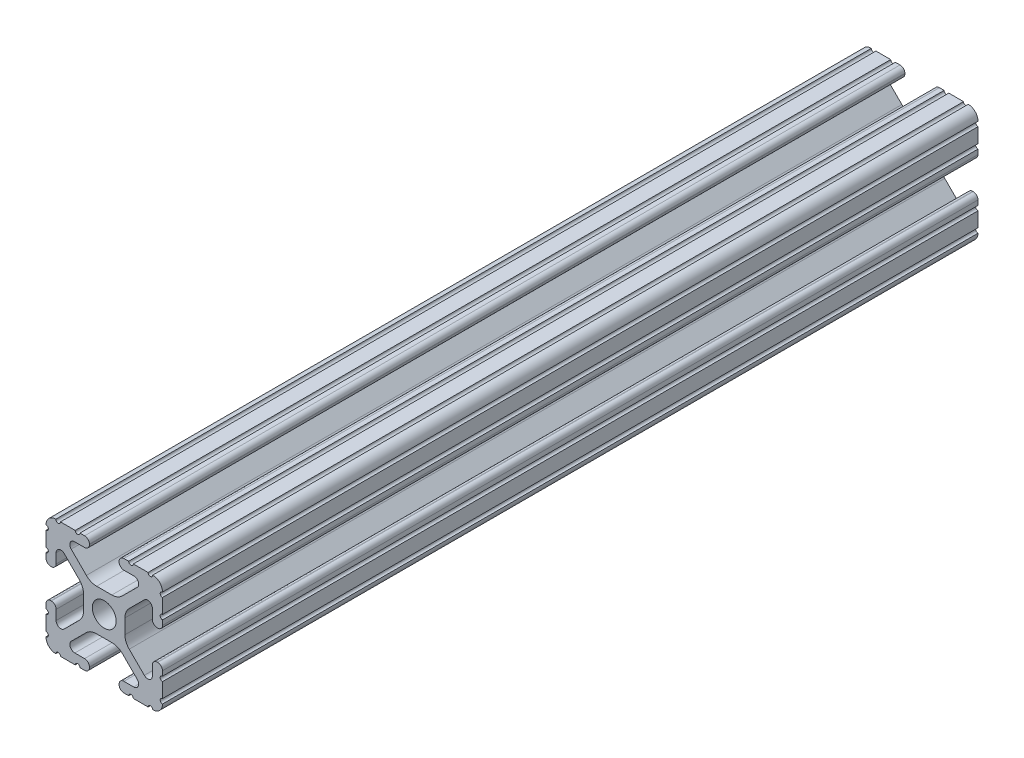
from build123d import *

# Parameters (mm, degrees)
SKETCH1_R           = 2.6035
BOSS_EXTRUDE1_DEPTH = 2463.8
CUT_EXTRUDE1_DEPTH  = 2286


with BuildPart() as part:
    # Sketch1 → Boss-Extrude1 (new body)
    with BuildSketch(Plane.XY):
        with BuildLine():
            Line((-1.709253557, -4.4958), (1.709253557, -4.4958))
            ThreePointArc((1.709253557, -4.4958), (2.922936451, -4.736929036), (3.952270251, -5.423690499))
            Line((3.952270251, -5.423690499), (7.179650497, -8.645192506))
            ThreePointArc((7.179650497, -8.645192506), (7.41473083, -9.822813117), (6.416408329, -10.4902))
            Line((6.416408329, -10.4902), (4.287512407, -10.4902))
            ThreePointArc((4.287512407, -10.4902), (3.54574862, -10.79744862), (3.2385, -11.539212407))
            Line((3.2385, -11.539212407), (3.2385, -11.650987593))
            ThreePointArc((3.2385, -11.650987593), (3.54574862, -12.39275138), (4.287512407, -12.7))
            Line((4.287512407, -12.7), (5.317126718, -12.7))
            ThreePointArc((5.317126718, -12.7), (5.825126718, -12.192), (6.333126718, -12.7))
            Line((6.333126718, -12.7), (9.550443118, -12.7))
            ThreePointArc((9.550443118, -12.7), (10.058366869, -12.192000006), (10.566443095, -12.699847501))
            ThreePointArc((10.566443095, -12.699847501), (12.082537762, -12.08250727), (12.699846982, -10.566399977))
            ThreePointArc((12.699846982, -10.566399977), (12.192000006, -10.058323491), (12.7, -9.5504))
            Line((12.7, -9.5504), (12.7, -6.3330836))
            ThreePointArc((12.7, -6.3330836), (12.192, -5.8250836), (12.7, -5.3170836))
            Line((12.7, -5.3170836), (12.7, -4.287469289))
            ThreePointArc((12.7, -4.287469289), (12.39275138, -3.545705502), (11.650987593, -3.238456882))
            Line((11.650987593, -3.238456882), (11.539212407, -3.238456882))
            ThreePointArc((11.539212407, -3.238456882), (10.79744862, -3.545705502), (10.4902, -4.287469289))
            Line((10.4902, -4.287469289), (10.4902, -6.402089023))
            ThreePointArc((10.4902, -6.402089023), (9.856505071, -7.351067942), (8.737131347, -7.129408934))
            Line((8.737131347, -7.129408934), (5.441005833, -3.840816462))
            ThreePointArc((5.441005833, -3.840816462), (4.750877967, -2.809883091), (4.5085, -1.593185507))
            Line((4.5085, -1.593185507), (4.5085, 1.593185507))
            ThreePointArc((4.5085, 1.593185507), (4.750877967, 2.809883091), (5.441005833, 3.840816462))
            Line((5.441005833, 3.840816462), (8.737131347, 7.129408934))
            ThreePointArc((8.737131347, 7.129408934), (9.856505071, 7.351067942), (10.4902, 6.402089023))
            Line((10.4902, 6.402089023), (10.4902, 4.287469289))
            ThreePointArc((10.4902, 4.287469289), (10.79744862, 3.545705502), (11.539212407, 3.238456882))
            Line((11.539212407, 3.238456882), (11.650987593, 3.238456882))
            ThreePointArc((11.650987593, 3.238456882), (12.39275138, 3.545705502), (12.7, 4.287469289))
            Line((12.7, 4.287469289), (12.7, 5.3170836))
            ThreePointArc((12.7, 5.3170836), (12.192, 5.8250836), (12.7, 6.3330836))
            Line((12.7, 6.3330836), (12.7, 9.5504))
            ThreePointArc((12.7, 9.5504), (12.192000006, 10.058323491), (12.699846982, 10.566399977))
            ThreePointArc((12.699846982, 10.566399977), (12.082537762, 12.08250727), (10.566443095, 12.699847501))
            ThreePointArc((10.566443095, 12.699847501), (10.058366869, 12.192000006), (9.550443118, 12.7))
            Line((9.550443118, 12.7), (6.333126718, 12.7))
            ThreePointArc((6.333126718, 12.7), (5.825126718, 12.192), (5.317126718, 12.7))
            Line((5.317126718, 12.7), (4.287512407, 12.7))
            ThreePointArc((4.287512407, 12.7), (3.54574862, 12.39275138), (3.2385, 11.650987593))
            Line((3.2385, 11.650987593), (3.2385, 11.539212407))
            ThreePointArc((3.2385, 11.539212407), (3.54574862, 10.79744862), (4.287512407, 10.4902))
            Line((4.287512407, 10.4902), (6.476788598, 10.4902))
            ThreePointArc((6.476788598, 10.4902), (7.432222385, 9.85140422), (7.207036008, 8.724370562))
            Line((7.207036008, 8.724370562), (3.898272566, 5.423169045))
            ThreePointArc((3.898272566, 5.423169045), (2.869120213, 4.736787962), (1.655778399, 4.4958))
            Line((1.655778399, 4.4958), (-1.655778399, 4.4958))
            ThreePointArc((-1.655778399, 4.4958), (-2.869120213, 4.736787962), (-3.898272566, 5.423169045))
            Line((-3.898272566, 5.423169045), (-7.207036008, 8.724370562))
            ThreePointArc((-7.207036008, 8.724370562), (-7.432222385, 9.85140422), (-6.476788598, 10.4902))
            Line((-6.476788598, 10.4902), (-4.287512407, 10.4902))
            ThreePointArc((-4.287512407, 10.4902), (-3.54574862, 10.79744862), (-3.2385, 11.539212407))
            Line((-3.2385, 11.539212407), (-3.2385, 11.650987593))
            ThreePointArc((-3.2385, 11.650987593), (-3.54574862, 12.39275138), (-4.287512407, 12.7))
            Line((-4.287512407, 12.7), (-5.317126718, 12.7))
            ThreePointArc((-5.317126718, 12.7), (-5.825126718, 12.192), (-6.333126718, 12.7))
            Line((-6.333126718, 12.7), (-9.550443118, 12.7))
            ThreePointArc((-9.550443118, 12.7), (-10.058366869, 12.192000006), (-10.566443095, 12.699847501))
            ThreePointArc((-10.566443095, 12.699847501), (-12.082537762, 12.08250727), (-12.699846982, 10.566399977))
            ThreePointArc((-12.699846982, 10.566399977), (-12.192000006, 10.058323491), (-12.7, 9.5504))
            Line((-12.7, 9.5504), (-12.7, 6.3330836))
            ThreePointArc((-12.7, 6.3330836), (-12.192, 5.8250836), (-12.7, 5.3170836))
            Line((-12.7, 5.3170836), (-12.7, 4.287469289))
            ThreePointArc((-12.7, 4.287469289), (-12.39275138, 3.545705502), (-11.650987593, 3.238456882))
            Line((-11.650987593, 3.238456882), (-11.539212407, 3.238456882))
            ThreePointArc((-11.539212407, 3.238456882), (-10.79744862, 3.545705502), (-10.4902, 4.287469289))
            Line((-10.4902, 4.287469289), (-10.4902, 6.402089023))
            ThreePointArc((-10.4902, 6.402089023), (-9.856505071, 7.351067942), (-8.737131347, 7.129408934))
            Line((-8.737131347, 7.129408934), (-5.441005833, 3.840816462))
            ThreePointArc((-5.441005833, 3.840816462), (-4.750877967, 2.809883091), (-4.5085, 1.593185507))
            Line((-4.5085, 1.593185507), (-4.5085, -1.593185507))
            ThreePointArc((-4.5085, -1.593185507), (-4.750877967, -2.809883091), (-5.441005833, -3.840816462))
            Line((-5.441005833, -3.840816462), (-8.737131347, -7.129408934))
            ThreePointArc((-8.737131347, -7.129408934), (-9.856505071, -7.351067942), (-10.4902, -6.402089023))
            Line((-10.4902, -6.402089023), (-10.4902, -4.287469289))
            ThreePointArc((-10.4902, -4.287469289), (-10.79744862, -3.545705502), (-11.539212407, -3.238456882))
            Line((-11.539212407, -3.238456882), (-11.650987593, -3.238456882))
            ThreePointArc((-11.650987593, -3.238456882), (-12.39275138, -3.545705502), (-12.7, -4.287469289))
            Line((-12.7, -4.287469289), (-12.7, -5.3170836))
            ThreePointArc((-12.7, -5.3170836), (-12.192, -5.8250836), (-12.7, -6.3330836))
            Line((-12.7, -6.3330836), (-12.7, -9.5504))
            ThreePointArc((-12.7, -9.5504), (-12.192000006, -10.058323491), (-12.699846982, -10.566399977))
            ThreePointArc((-12.699846982, -10.566399977), (-12.082537762, -12.08250727), (-10.566443095, -12.699847501))
            ThreePointArc((-10.566443095, -12.699847501), (-10.058366869, -12.192000006), (-9.550443118, -12.7))
            Line((-9.550443118, -12.7), (-6.333126718, -12.7))
            ThreePointArc((-6.333126718, -12.7), (-5.825126718, -12.192), (-5.317126718, -12.7))
            Line((-5.317126718, -12.7), (-4.287512407, -12.7))
            ThreePointArc((-4.287512407, -12.7), (-3.54574862, -12.39275138), (-3.2385, -11.650987593))
            Line((-3.2385, -11.650987593), (-3.2385, -11.539212407))
            ThreePointArc((-3.2385, -11.539212407), (-3.54574862, -10.79744862), (-4.287512407, -10.4902))
            Line((-4.287512407, -10.4902), (-6.416408329, -10.4902))
            ThreePointArc((-6.416408329, -10.4902), (-7.41473083, -9.822813117), (-7.179650497, -8.645192506))
            Line((-7.179650497, -8.645192506), (-3.952270251, -5.423690499))
            ThreePointArc((-3.952270251, -5.423690499), (-2.922936451, -4.736929036), (-1.709253557, -4.4958))
        make_face()
        Circle(SKETCH1_R, mode=Mode.SUBTRACT)
    extrude(amount=BOSS_EXTRUDE1_DEPTH)

    # Sketch2 → Cut-Extrude1 (cut)
    with BuildSketch(Plane.XY.offset(2463.8)):
        with BuildLine():
            Line((-1.709253557, -4.4958), (1.709253557, -4.4958))
            ThreePointArc((1.709253557, -4.4958), (2.922936451, -4.736929036), (3.952270251, -5.423690499))
            Line((3.952270251, -5.423690499), (7.179650497, -8.645192506))
            ThreePointArc((7.179650497, -8.645192506), (7.41473083, -9.822813117), (6.416408329, -10.4902))
            Line((6.416408329, -10.4902), (4.287512407, -10.4902))
            ThreePointArc((4.287512407, -10.4902), (3.54574862, -10.79744862), (3.2385, -11.539212407))
            Line((3.2385, -11.539212407), (3.2385, -11.650987593))
            ThreePointArc((3.2385, -11.650987593), (3.54574862, -12.39275138), (4.287512407, -12.7))
            Line((4.287512407, -12.7), (5.317126718, -12.7))
            ThreePointArc((5.317126718, -12.7), (5.825126718, -12.192), (6.333126718, -12.7))
            Line((6.333126718, -12.7), (9.550443118, -12.7))
            ThreePointArc((9.550443118, -12.7), (10.058366869, -12.192000006), (10.566443095, -12.699847501))
            ThreePointArc((10.566443095, -12.699847501), (12.082537762, -12.08250727), (12.699846982, -10.566399977))
            ThreePointArc((12.699846982, -10.566399977), (12.192000006, -10.058323491), (12.7, -9.5504))
            Line((12.7, -9.5504), (12.7, -6.3330836))
            ThreePointArc((12.7, -6.3330836), (12.192, -5.8250836), (12.7, -5.3170836))
            Line((12.7, -5.3170836), (12.7, -4.287469289))
            ThreePointArc((12.7, -4.287469289), (12.39275138, -3.545705502), (11.650987593, -3.238456882))
            Line((11.650987593, -3.238456882), (11.539212407, -3.238456882))
            ThreePointArc((11.539212407, -3.238456882), (10.79744862, -3.545705502), (10.4902, -4.287469289))
            Line((10.4902, -4.287469289), (10.4902, -6.402089023))
            ThreePointArc((10.4902, -6.402089023), (9.856505071, -7.351067942), (8.737131347, -7.129408934))
            Line((8.737131347, -7.129408934), (5.441005833, -3.840816462))
            ThreePointArc((5.441005833, -3.840816462), (4.750877967, -2.809883091), (4.5085, -1.593185507))
            Line((4.5085, -1.593185507), (4.5085, 1.593185507))
            ThreePointArc((4.5085, 1.593185507), (4.750877967, 2.809883091), (5.441005833, 3.840816462))
            Line((5.441005833, 3.840816462), (8.737131347, 7.129408934))
            ThreePointArc((8.737131347, 7.129408934), (9.856505071, 7.351067942), (10.4902, 6.402089023))
            Line((10.4902, 6.402089023), (10.4902, 4.287469289))
            ThreePointArc((10.4902, 4.287469289), (10.79744862, 3.545705502), (11.539212407, 3.238456882))
            Line((11.539212407, 3.238456882), (11.650987593, 3.238456882))
            ThreePointArc((11.650987593, 3.238456882), (12.39275138, 3.545705502), (12.7, 4.287469289))
            Line((12.7, 4.287469289), (12.7, 5.3170836))
            ThreePointArc((12.7, 5.3170836), (12.192, 5.8250836), (12.7, 6.3330836))
            Line((12.7, 6.3330836), (12.7, 9.5504))
            ThreePointArc((12.7, 9.5504), (12.192000006, 10.058323491), (12.699846982, 10.566399977))
            ThreePointArc((12.699846982, 10.566399977), (12.082537762, 12.08250727), (10.566443095, 12.699847501))
            ThreePointArc((10.566443095, 12.699847501), (10.058366869, 12.192000006), (9.550443118, 12.7))
            Line((9.550443118, 12.7), (6.333126718, 12.7))
            ThreePointArc((6.333126718, 12.7), (5.825126718, 12.192), (5.317126718, 12.7))
            Line((5.317126718, 12.7), (4.287512407, 12.7))
            ThreePointArc((4.287512407, 12.7), (3.54574862, 12.39275138), (3.2385, 11.650987593))
            Line((3.2385, 11.650987593), (3.2385, 11.539212407))
            ThreePointArc((3.2385, 11.539212407), (3.54574862, 10.79744862), (4.287512407, 10.4902))
            Line((4.287512407, 10.4902), (6.476788598, 10.4902))
            ThreePointArc((6.476788598, 10.4902), (7.432222385, 9.85140422), (7.207036008, 8.724370562))
            Line((7.207036008, 8.724370562), (3.898272566, 5.423169045))
            ThreePointArc((3.898272566, 5.423169045), (2.869120213, 4.736787962), (1.655778399, 4.4958))
            Line((1.655778399, 4.4958), (-1.655778399, 4.4958))
            ThreePointArc((-1.655778399, 4.4958), (-2.869120213, 4.736787962), (-3.898272566, 5.423169045))
            Line((-3.898272566, 5.423169045), (-7.207036008, 8.724370562))
            ThreePointArc((-7.207036008, 8.724370562), (-7.432222385, 9.85140422), (-6.476788598, 10.4902))
            Line((-6.476788598, 10.4902), (-4.287512407, 10.4902))
            ThreePointArc((-4.287512407, 10.4902), (-3.54574862, 10.79744862), (-3.2385, 11.539212407))
            Line((-3.2385, 11.539212407), (-3.2385, 11.650987593))
            ThreePointArc((-3.2385, 11.650987593), (-3.54574862, 12.39275138), (-4.287512407, 12.7))
            Line((-4.287512407, 12.7), (-5.317126718, 12.7))
            ThreePointArc((-5.317126718, 12.7), (-5.825126718, 12.192), (-6.333126718, 12.7))
            Line((-6.333126718, 12.7), (-9.550443118, 12.7))
            ThreePointArc((-9.550443118, 12.7), (-10.058366869, 12.192000006), (-10.566443095, 12.699847501))
            ThreePointArc((-10.566443095, 12.699847501), (-12.082537762, 12.08250727), (-12.699846982, 10.566399977))
            ThreePointArc((-12.699846982, 10.566399977), (-12.192000006, 10.058323491), (-12.7, 9.5504))
            Line((-12.7, 9.5504), (-12.7, 6.3330836))
            ThreePointArc((-12.7, 6.3330836), (-12.192, 5.8250836), (-12.7, 5.3170836))
            Line((-12.7, 5.3170836), (-12.7, 4.287469289))
            ThreePointArc((-12.7, 4.287469289), (-12.39275138, 3.545705502), (-11.650987593, 3.238456882))
            Line((-11.650987593, 3.238456882), (-11.539212407, 3.238456882))
            ThreePointArc((-11.539212407, 3.238456882), (-10.79744862, 3.545705502), (-10.4902, 4.287469289))
            Line((-10.4902, 4.287469289), (-10.4902, 6.402089023))
            ThreePointArc((-10.4902, 6.402089023), (-9.856505071, 7.351067942), (-8.737131347, 7.129408934))
            Line((-8.737131347, 7.129408934), (-5.441005833, 3.840816462))
            ThreePointArc((-5.441005833, 3.840816462), (-4.750877967, 2.809883091), (-4.5085, 1.593185507))
            Line((-4.5085, 1.593185507), (-4.5085, -1.593185507))
            ThreePointArc((-4.5085, -1.593185507), (-4.750877967, -2.809883091), (-5.441005833, -3.840816462))
            Line((-5.441005833, -3.840816462), (-8.737131347, -7.129408934))
            ThreePointArc((-8.737131347, -7.129408934), (-9.856505071, -7.351067942), (-10.4902, -6.402089023))
            Line((-10.4902, -6.402089023), (-10.4902, -4.287469289))
            ThreePointArc((-10.4902, -4.287469289), (-10.79744862, -3.545705502), (-11.539212407, -3.238456882))
            Line((-11.539212407, -3.238456882), (-11.650987593, -3.238456882))
            ThreePointArc((-11.650987593, -3.238456882), (-12.39275138, -3.545705502), (-12.7, -4.287469289))
            Line((-12.7, -4.287469289), (-12.7, -5.3170836))
            ThreePointArc((-12.7, -5.3170836), (-12.192, -5.8250836), (-12.7, -6.3330836))
            Line((-12.7, -6.3330836), (-12.7, -9.5504))
            ThreePointArc((-12.7, -9.5504), (-12.192000006, -10.058323491), (-12.699846982, -10.566399977))
            ThreePointArc((-12.699846982, -10.566399977), (-12.082537762, -12.08250727), (-10.566443095, -12.699847501))
            ThreePointArc((-10.566443095, -12.699847501), (-10.058366869, -12.192000006), (-9.550443118, -12.7))
            Line((-9.550443118, -12.7), (-6.333126718, -12.7))
            ThreePointArc((-6.333126718, -12.7), (-5.825126718, -12.192), (-5.317126718, -12.7))
            Line((-5.317126718, -12.7), (-4.287512407, -12.7))
            ThreePointArc((-4.287512407, -12.7), (-3.54574862, -12.39275138), (-3.2385, -11.650987593))
            Line((-3.2385, -11.650987593), (-3.2385, -11.539212407))
            ThreePointArc((-3.2385, -11.539212407), (-3.54574862, -10.79744862), (-4.287512407, -10.4902))
            Line((-4.287512407, -10.4902), (-6.416408329, -10.4902))
            ThreePointArc((-6.416408329, -10.4902), (-7.41473083, -9.822813117), (-7.179650497, -8.645192506))
            Line((-7.179650497, -8.645192506), (-3.952270251, -5.423690499))
            ThreePointArc((-3.952270251, -5.423690499), (-2.922936451, -4.736929036), (-1.709253557, -4.4958))
        make_face()
    extrude(amount=-CUT_EXTRUDE1_DEPTH, mode=Mode.SUBTRACT)


solid = part.part
